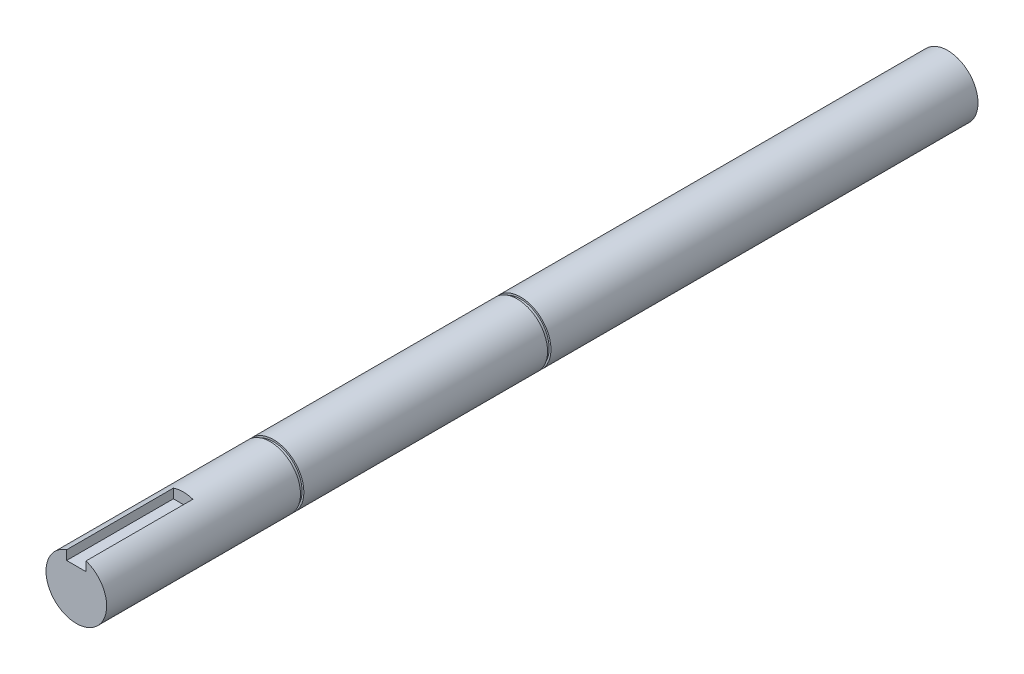
from build123d import *

# Parameters (mm, degrees)
SKETCH_1_R          = 12.5
EXTRUDE_1_DEPTH     = 359
CUT_EXTRUDE_START   = -44
SKETCH_2_W          = 8
SKETCH_2_H          = 8.5
CUT_EXTRUDE_1_DEPTH = 44
SKETCH_3_W          = 1.4
SKETCH_3_H          = 2.395884976
SKETCH_3_H_2        = 2.262849939


with BuildPart() as part:
    # Эскиз1 → Бобышка-Вытянуть1 (new body)
    with BuildSketch(Plane.XY):
        Circle(SKETCH_1_R)
    extrude(amount=-EXTRUDE_1_DEPTH)

    # Эскиз2 → Вырез-Вытянуть1 (cut)
    with BuildSketch(Plane.XY.offset(CUT_EXTRUDE_START)):
        with Locations((0, 12.25)):
            Rectangle(SKETCH_2_W, SKETCH_2_H)
    extrude(amount=CUT_EXTRUDE_1_DEPTH, mode=Mode.SUBTRACT)

    # Эскиз3 → Вырез-Повернуть1 (revolve, cut)
    with BuildSketch(Plane(origin=(0, 0, 0), x_dir=(0, 0, -1), z_dir=(1, 0, 0))):
        with Locations((182.35, 12.947942488)):
            Rectangle(SKETCH_3_W, SKETCH_3_H)
        with Locations((80.55, 12.881424969)):
            Rectangle(SKETCH_3_W, SKETCH_3_H_2)
    revolve(axis=Axis((0, 0, 1000), (0, 0, -1)), mode=Mode.SUBTRACT)


solid = part.part
